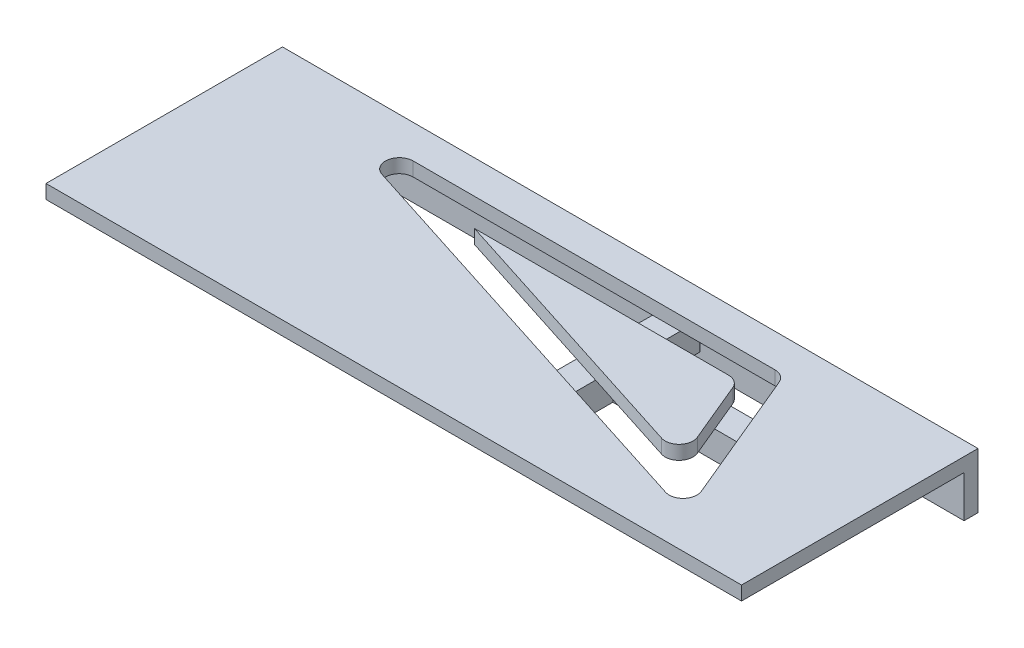
from build123d import *

# Parameters (mm, degrees)
SKETCH1_W           = 250
SKETCH1_H           = 20
BOSS_EXTRUDE1_DEPTH = 5
SKETCH2_W           = 250
SKETCH2_H           = 5
BOSS_EXTRUDE2_DEPTH = 80
BOSS_EXTRUDE3_DEPTH = 10
CUT_EXTRUDE2_DEPTH  = 10


with BuildPart() as part:
    # Sketch1 → Boss-Extrude1 (new body)
    with BuildSketch(Plane.XY):
        with Locations((125, 10)):
            Rectangle(SKETCH1_W, SKETCH1_H)
    extrude(amount=BOSS_EXTRUDE1_DEPTH)

    # Sketch2 → Boss-Extrude2 (add)
    with BuildSketch(Plane.XY.offset(5)):
        with Locations((125, 17.5)):
            Rectangle(SKETCH2_W, SKETCH2_H)
    extrude(amount=BOSS_EXTRUDE2_DEPTH)

    # Sketch4 → Boss-Extrude3 (add)
    with BuildSketch(Plane.XZ.offset(-15)):
        with BuildLine():
            Line((145, 31.244995812), (145, 65.71985119))
            ThreePointArc((145, 65.71985119), (150, 70.71985119), (155, 65.71985119))
            Line((155, 65.71985119), (155, 36.244995812))
            Line((155, 36.244995812), (214.286235525, 36.244995812))
            ThreePointArc((214.286235525, 36.244995812), (219.286235525, 31.244995812), (214.286235525, 26.244995812))
            Line((214.286235525, 26.244995812), (155, 26.244995812))
            Line((155, 26.244995812), (155, 5.178641746))
            ThreePointArc((155, 5.178641746), (150, 0.178641746), (145, 5.178641746))
            Line((145, 5.178641746), (145, 31.244995812))
        make_face()
    extrude(amount=BOSS_EXTRUDE3_DEPTH)

    # Sketch3 → Cut-Extrude2 (cut)
    with BuildSketch(Plane.XZ.offset(-15)):
        with BuildLine():
            Line((207.476121364, 69.762120736), (57.476121364, 21.762120736))
            ThreePointArc((57.476121364, 21.762120736), (54.059827752, 16.228833248), (59, 12))
            Line((59, 12), (189, 12))
            ThreePointArc((189, 12), (191.773500981, 12.839748528), (193.615384615, 15.076923077))
            Line((193.615384615, 15.076923077), (213.615384615, 63.076923077))
            ThreePointArc((213.615384615, 63.076923077), (212.682705424, 68.381964039), (207.476121364, 69.762120736))
        make_face()
        with BuildLine():
            Line((189.928273384, 53.647285584), (91.030505936, 22))
            Line((91.030505936, 22), (182.333333333, 22))
            ThreePointArc((182.333333333, 22), (185.106834314, 22.839748528), (186.948717949, 25.076923077))
            Line((186.948717949, 25.076923077), (196.067536635, 46.962087925))
            ThreePointArc((196.067536635, 46.962087925), (195.134857444, 52.267128886), (189.928273384, 53.647285584))
        make_face(mode=Mode.SUBTRACT)
    extrude(amount=-CUT_EXTRUDE2_DEPTH, mode=Mode.SUBTRACT)


solid = part.part
